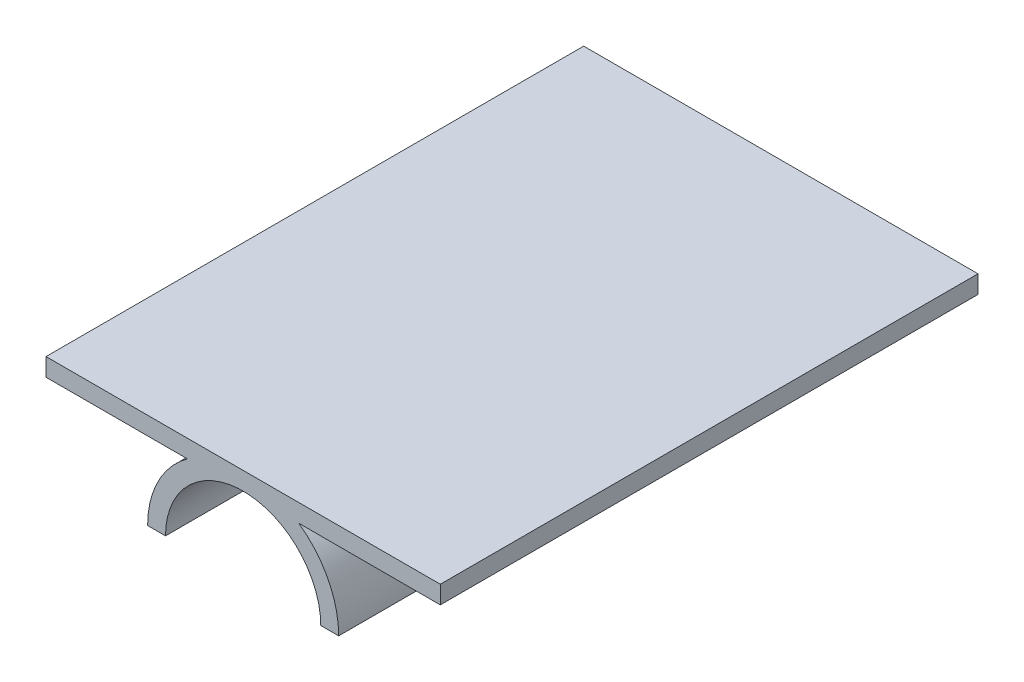
from build123d import *

# Parameters (mm, degrees)
BOSS_EXTRUDE1_DEPTH = 76.2


with BuildPart() as part:
    # Sketch1 → Boss-Extrude1 (new body)
    with BuildSketch(Plane.XY):
        with BuildLine():
            Line((-11, 0), (-13.54, 0))
            ThreePointArc((-13.54, 0), (-12.046376905, 6.181941723), (-7.895036415, 11))
            Line((-7.895036415, 11), (-27.94, 11))
            Line((-27.94, 11), (-27.94, 13.54))
            Line((-27.94, 13.54), (27.94, 13.54))
            Line((27.94, 13.54), (27.94, 11))
            Line((27.94, 11), (7.895036415, 11))
            ThreePointArc((7.895036415, 11), (12.046376905, 6.181941723), (13.54, 0))
            Line((13.54, 0), (11, 0))
            ThreePointArc((11, 0), (0, 11), (-11, 0))
        make_face()
    extrude(amount=BOSS_EXTRUDE1_DEPTH)


solid = part.part
